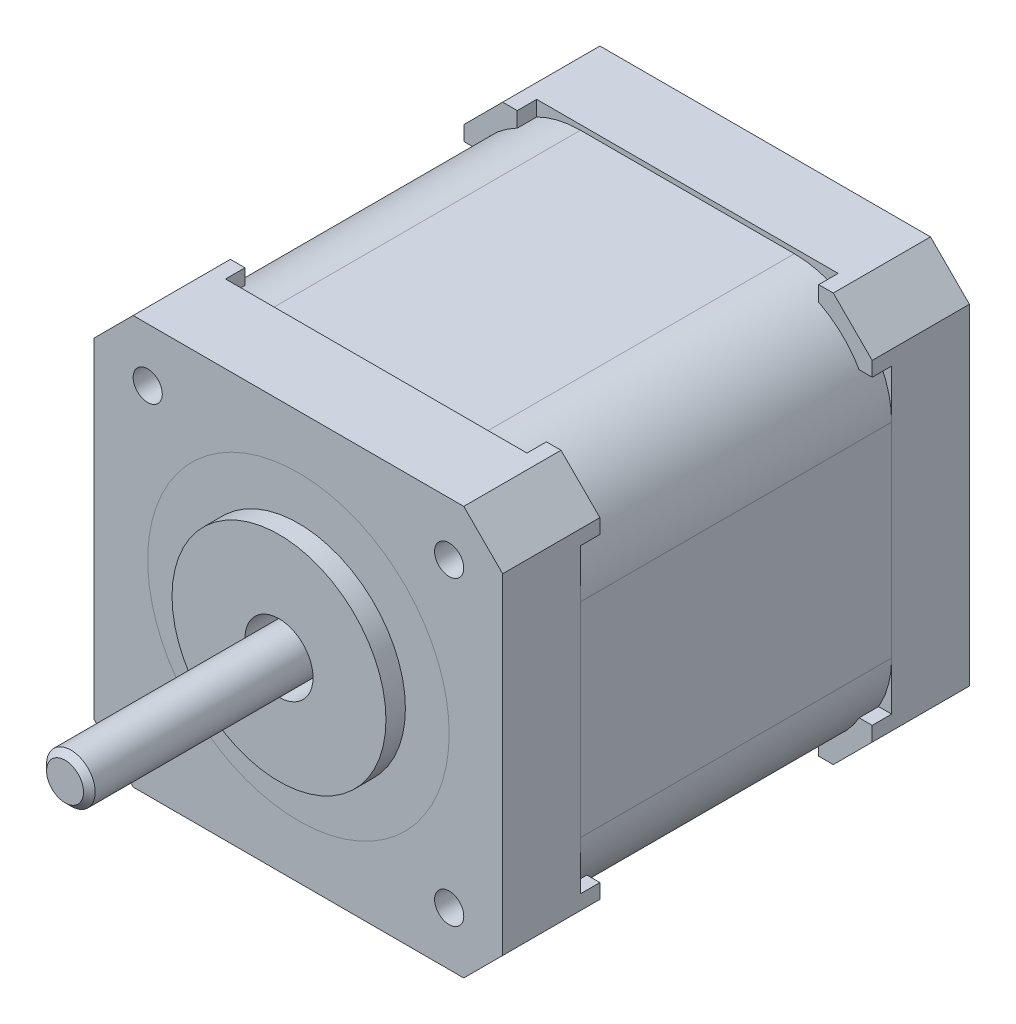
from build123d import *

# Parameters (mm, degrees)
SALIENTE_EXTRUIR1_DEPTH = 24
CORTAR_EXTRUIR1_START   = -8
CROQUIS2_W              = 31
CROQUIS2_H              = 5.5
CROQUIS2_H_2            = 31
CROQUIS2_W_2            = 5.5
CORTAR_EXTRUIR1_DEPTH   = 32
CORTAR_EXTRUIR2_START   = -10
CORTAR_EXTRUIR2_DEPTH   = 28
CORTAR_EXTRUIR3_START   = -40
CORTAR_EXTRUIR3_DEPTH   = 32
SALIENTE_EXTRUIR2_START = -40
SALIENTE_EXTRUIR2_DEPTH = 32
CROQUIS5_R              = 15.5
CROQUIS5_R_2            = 11
CROQUIS5_R_3            = 3.5
CROQUIS5_R_4            = 2.5
CORTAR_EXTRUIR4_DEPTH   = 3
CROQUIS5_3_R            = 15.5
CROQUIS5_3_R_2          = 11
SALIENTE_EXTRUIR3_DEPTH = 3
SALIENTE_EXTRUIR4_START = -3
CROQUIS5_4_R            = 11
CROQUIS5_4_R_2          = 3.5
SALIENTE_EXTRUIR4_DEPTH = 5
SALIENTE_EXTRUIR5_START = -3
CROQUIS5_5_R            = 2.5
SALIENTE_EXTRUIR5_DEPTH = 27
CHAFL_N1_SIZE           = 0.6
CROQUIS6_R              = 1.5
CORTAR_EXTRUIR5_DEPTH   = 4.5
SKETCH1_W               = 7
SKETCH1_H               = 9
CUT_EXTRUDE1_DEPTH      = 0.5


with BuildPart() as part:
    # Croquis1 → Saliente-Extruir1 (new body, symmetric)
    with BuildSketch(Plane.XY):
        Polygon((-17, 21), (-21, 17), (-21, -17), (-17, -21), (17, -21), (21, -17), (21, 17), (17, 21), align=None)
    extrude(amount=SALIENTE_EXTRUIR1_DEPTH, both=True)

    # Croquis2 → Cortar-Extruir1 (cut)
    with BuildSketch(Plane.XY.offset(24).offset(CORTAR_EXTRUIR1_START)):
        with Locations((0, 18.25)):
            Rectangle(CROQUIS2_W, CROQUIS2_H)
        Rectangle(CROQUIS2_W, CROQUIS2_H_2)
        with Locations((18.25, 0)):
            Rectangle(CROQUIS2_W_2, CROQUIS2_H_2)
        with Locations((0, -18.25)):
            Rectangle(CROQUIS2_W, CROQUIS2_H)
        with Locations((-18.25, 0)):
            Rectangle(CROQUIS2_W_2, CROQUIS2_H_2)
    extrude(amount=-CORTAR_EXTRUIR1_DEPTH, mode=Mode.SUBTRACT)

    # Croquis3 → Cortar-Extruir2 (cut)
    with BuildSketch(Plane(origin=(0, 0, -24), x_dir=(-1, 0, 0), z_dir=(0, 0, -1)).offset(CORTAR_EXTRUIR2_START)):
        Polygon((-17, 21), (-21, 17), (-21, -17), (-17, -21), (17, -21), (21, -17), (21, 17), (17, 21), align=None)
    extrude(amount=-CORTAR_EXTRUIR2_DEPTH, mode=Mode.SUBTRACT)

    # Croquis4_4 → Cortar-Extruir3 (cut)
    with BuildSketch(Plane.XY.offset(24).offset(CORTAR_EXTRUIR3_START)):
        with BuildLine():
            Line((-21, 10.5), (-21, -10.5))
            ThreePointArc((-21, -10.5), (-18.071067812, -17.571067812), (-11, -20.5))
            Line((-11, -20.5), (11, -20.5))
            ThreePointArc((11, -20.5), (18.071067812, -17.571067812), (21, -10.5))
            Line((21, -10.5), (21, 10.5))
            ThreePointArc((21, 10.5), (18.071067812, 17.571067812), (11, 20.5))
            Line((11, 20.5), (-11, 20.5))
            ThreePointArc((-11, 20.5), (-18.071067812, 17.571067812), (-21, 10.5))
        make_face()
    extrude(amount=CORTAR_EXTRUIR3_DEPTH, mode=Mode.SUBTRACT)

    # Croquis5 → Cortar-Extruir4 (cut)
    with BuildSketch(Plane.XY.offset(24)):
        Circle(CROQUIS5_R)
        Circle(CROQUIS5_R_2, mode=Mode.SUBTRACT)
        Circle(CROQUIS5_R_2)
        Circle(CROQUIS5_R_3, mode=Mode.SUBTRACT)
        Circle(CROQUIS5_R_3)
        Circle(CROQUIS5_R_4, mode=Mode.SUBTRACT)
        Circle(CROQUIS5_R_4)
    extrude(amount=-CORTAR_EXTRUIR4_DEPTH, mode=Mode.SUBTRACT)

    # Croquis5_5 → Saliente-Extruir5 (add)
    with BuildSketch(Plane.XY.offset(24).offset(SALIENTE_EXTRUIR5_START)):
        Circle(CROQUIS5_5_R)
    extrude(amount=SALIENTE_EXTRUIR5_DEPTH)

    # Chafl_n1
    chafl_n1_edges = [part.edges().sort_by_distance(p)[0] for p in [
        (-2.5, 0, 48),
    ]]
    chamfer(chafl_n1_edges, length=CHAFL_N1_SIZE)

    # Croquis6 → Cortar-Extruir5 (cut)
    with BuildSketch(Plane.XY.offset(24)):
        with Locations((-15.5, -15.5)):
            Circle(CROQUIS6_R)
        with Locations((15.5, -15.5)):
            Circle(CROQUIS6_R)
        with Locations((15.5, 15.5)):
            Circle(CROQUIS6_R)
        with Locations((-15.5, 15.5)):
            Circle(CROQUIS6_R)
    extrude(amount=-CORTAR_EXTRUIR5_DEPTH, mode=Mode.SUBTRACT)

    # Sketch1 → Cut-Extrude1 (cut)
    with BuildSketch(Plane.ZY.offset(21)):
        with Locations((-19.5, 0)):
            Rectangle(SKETCH1_W, SKETCH1_H)
    extrude(amount=-CUT_EXTRUDE1_DEPTH, mode=Mode.SUBTRACT)


with BuildPart() as body_2:
    # Croquis4 → Saliente-Extruir2 (new body)
    with BuildSketch(Plane.XY.offset(24).offset(SALIENTE_EXTRUIR2_START)):
        with BuildLine():
            Line((-21, 10.5), (-21, -10.5))
            ThreePointArc((-21, -10.5), (-18.071067812, -17.571067812), (-11, -20.5))
            Line((-11, -20.5), (11, -20.5))
            ThreePointArc((11, -20.5), (18.071067812, -17.571067812), (21, -10.5))
            Line((21, -10.5), (21, 10.5))
            ThreePointArc((21, 10.5), (18.071067812, 17.571067812), (11, 20.5))
            Line((11, 20.5), (-11, 20.5))
            ThreePointArc((-11, 20.5), (-18.071067812, 17.571067812), (-21, 10.5))
        make_face()
    extrude(amount=SALIENTE_EXTRUIR2_DEPTH)


with BuildPart() as body_3:
    # Croquis5_3 → Saliente-Extruir3 (new body)
    with BuildSketch(Plane.XY.offset(24)):
        Circle(CROQUIS5_3_R)
        Circle(CROQUIS5_3_R_2, mode=Mode.SUBTRACT)
    extrude(amount=-SALIENTE_EXTRUIR3_DEPTH)

    # Croquis5_4 → Saliente-Extruir4 (add)
    with BuildSketch(Plane.XY.offset(24).offset(SALIENTE_EXTRUIR4_START)):
        Circle(CROQUIS5_4_R)
        Circle(CROQUIS5_4_R_2, mode=Mode.SUBTRACT)
    extrude(amount=SALIENTE_EXTRUIR4_DEPTH)


solid = Compound([part.part, body_2.part, body_3.part])
